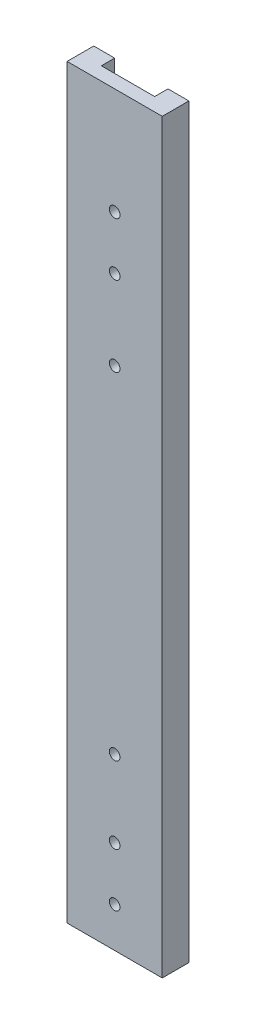
from build123d import *

# Parameters (mm, degrees)
SKETCH1_W           = 45.339
SKETCH1_H           = 355.6
BOSS_EXTRUDE1_DEPTH = 12.7
SKETCH2_W           = 25.4
SKETCH2_H           = 355.6
CUT_EXTRUDE1_DEPTH  = 6.35
SKETCH3_R           = 2.54
CUT_EXTRUDE2_DEPTH  = 7.35


with BuildPart() as part:
    # Sketch1 → Boss-Extrude1 (new body)
    with BuildSketch(Plane.XY):
        with Locations((22.6695, 177.8)):
            Rectangle(SKETCH1_W, SKETCH1_H)
    extrude(amount=BOSS_EXTRUDE1_DEPTH)

    # Sketch2 → Cut-Extrude1 (cut)
    with BuildSketch(Plane(origin=(0, 0, 0), x_dir=(-1, 0, 0), z_dir=(0, 0, -1))):
        with Locations((-22.6695, 177.8)):
            Rectangle(SKETCH2_W, SKETCH2_H)
    extrude(amount=-CUT_EXTRUDE1_DEPTH, mode=Mode.SUBTRACT)

    # Sketch3 → Cut-Extrude2 (cut, through all)
    with BuildSketch(Plane(origin=(0, 0, 6.35), x_dir=(-1, 0, 0), z_dir=(0, 0, -1))):
        with Locations((-22.6695, 19.05)):
            Circle(SKETCH3_R)
        with Locations((-22.6695, 44.45)):
            Circle(SKETCH3_R)
        with Locations((-22.6695, 304.8)):
            Circle(SKETCH3_R)
        with Locations((-22.6695, 279.4)):
            Circle(SKETCH3_R)
        with Locations((-22.6695, 241.3)):
            Circle(SKETCH3_R)
        with Locations((-22.6695, 80.9625)):
            Circle(SKETCH3_R)
    extrude(amount=-CUT_EXTRUDE2_DEPTH, mode=Mode.SUBTRACT)


solid = part.part
